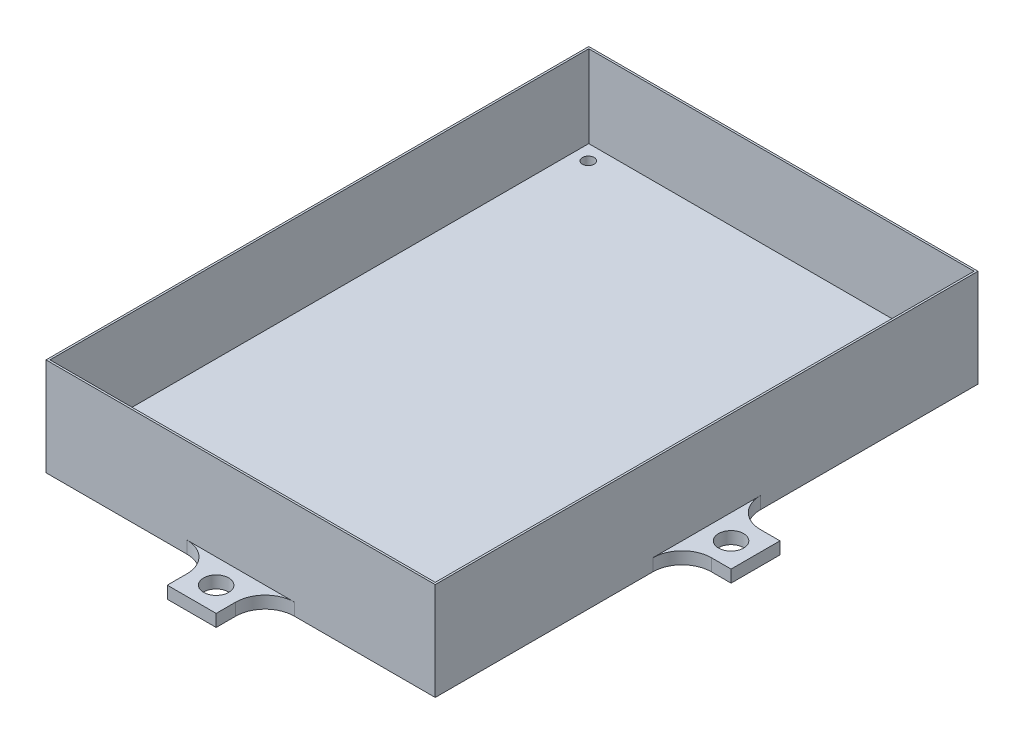
from build123d import *

# Parameters (mm, degrees)
SKETCH1_W                = 101.092
SKETCH1_H                = 140.97
BOSS_EXTRUDE1_DEPTH      = 25.4
SKETCH2_W                = 100.076
SKETCH2_H                = 139.954
CUT_EXTRUDE1_DEPTH       = 21.336
SKETCH3_R                = 1.524
CUT_EXTRUDE2_DEPTH       = 21.336
SKETCH4_W                = 12.7
SKETCH4_H                = 3.175
BOSS_EXTRUDE2_DEPTH      = 12.7
F_5_16_18_TAPPED_HOLE1_D = 6.5278
SKETCH13_W               = 12.7
SKETCH13_H               = 3.175
BOSS_EXTRUDE3_DEPTH      = 12.7
F_5_16_18_TAPPED_HOLE2_D = 6.5278
FILLET1_R                = 7.62


with BuildPart() as part:
    # Sketch1 → Boss-Extrude1 (new body)
    with BuildSketch(Plane(origin=(0, 0, 0), x_dir=(1, 0, 0), z_dir=(0, 1, 0))):
        with Locations((50.546, 70.485)):
            Rectangle(SKETCH1_W, SKETCH1_H)
    extrude(amount=BOSS_EXTRUDE1_DEPTH)

    # Sketch2 → Cut-Extrude1 (cut)
    with BuildSketch(Plane(origin=(0, 25.4, 0), x_dir=(1, 0, 0), z_dir=(0, 1, 0))):
        with Locations((50.546, 70.485)):
            Rectangle(SKETCH2_W, SKETCH2_H)
    extrude(amount=-CUT_EXTRUDE1_DEPTH, mode=Mode.SUBTRACT)

    # Sketch3 → Cut-Extrude2 (cut)
    with BuildSketch(Plane(origin=(0, 4.064, 0), x_dir=(1, 0, 0), z_dir=(0, 1, 0))):
        with Locations((4.318, 136.525)):
            Circle(SKETCH3_R)
        with Locations((96.774, 136.525)):
            Circle(SKETCH3_R)
        with Locations((96.774, 4.191)):
            Circle(SKETCH3_R)
        with Locations((4.318, 4.191)):
            Circle(SKETCH3_R)
    extrude(amount=-CUT_EXTRUDE2_DEPTH, mode=Mode.SUBTRACT)

    # Sketch4 → Boss-Extrude2 (add)
    with BuildSketch(Plane(origin=(0, 0, -140.97), x_dir=(-1, 0, 0), z_dir=(0, 0, -1))):
        with Locations((-50.546, 1.5875)):
            Rectangle(SKETCH4_W, SKETCH4_H)
    boss_extrude2 = extrude(amount=BOSS_EXTRUDE2_DEPTH)

    # 5/16-18 Tapped Hole1 (through all)
    with Locations(Plane(origin=(0, 3.175, 0), x_dir=(1, 0, 0), z_dir=(0, 1, 0))):
        with Locations((50.546, 147.32)):
            f_5_16_18_tapped_hole1 = Hole(F_5_16_18_TAPPED_HOLE1_D / 2)

    # Mirror1: Boss-Extrude2, 5/16-18 Tapped Hole1 across plane
    add(boss_extrude2.mirror(Plane.XY.offset(-70.485)))
    add(f_5_16_18_tapped_hole1.mirror(Plane.XY.offset(-70.485)), mode=Mode.SUBTRACT)

    # Sketch13 → Boss-Extrude3 (add)
    with BuildSketch(Plane.ZY):
        with Locations((-70.485, 1.5875)):
            Rectangle(SKETCH13_W, SKETCH13_H)
    boss_extrude3 = extrude(amount=BOSS_EXTRUDE3_DEPTH)

    # 5/16-18 Tapped Hole2 (through all)
    with Locations(Plane(origin=(0, 3.175, 0), x_dir=(1, 0, 0), z_dir=(0, 1, 0))):
        with Locations((-6.35, 70.485)):
            f_5_16_18_tapped_hole2 = Hole(F_5_16_18_TAPPED_HOLE2_D / 2)

    # Mirror2: Boss-Extrude3, 5/16-18 Tapped Hole2 across plane
    add(boss_extrude3.mirror(Plane.ZY.offset(-50.546)))
    add(f_5_16_18_tapped_hole2.mirror(Plane.ZY.offset(-50.546)), mode=Mode.SUBTRACT)

    # Fillet1
    fillet1_edges = [part.edges().sort_by_distance(p)[0] for p in [
        (101.092, 1.5875, -64.135),
        (101.092, 1.5875, -76.835),
        (56.896, 1.5875, -140.97),
        (44.196, 1.5875, -140.97),
        (56.896, 1.5875, 0),
        (44.196, 1.5875, 0),
        (0, 1.5875, -64.135),
        (0, 1.5875, -76.835),
    ]]
    fillet(fillet1_edges, radius=FILLET1_R)


solid = part.part
